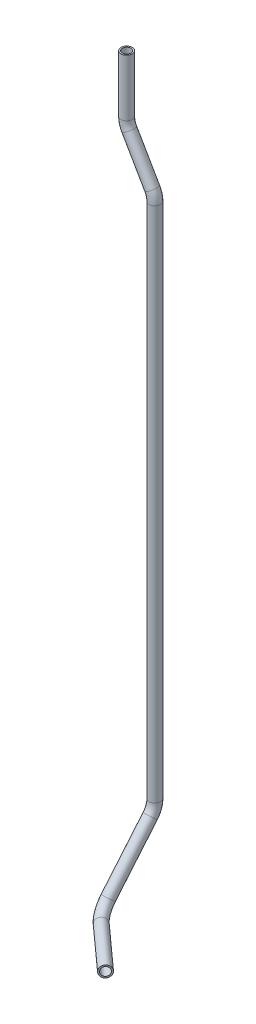
from build123d import *

# Parameters (mm, degrees)
SKETCH2_R   = 6
SKETCH2_R_2 = 4.5


with BuildPart() as part:
    # Sweep1: sweep along a curve in space
    with BuildLine() as sweep1_path:
        Line((0, 0, 0), (0, -60.373066959, 0))
        ThreePointArc((0, -60.373066959, 0), (0.715557648, -65.808266906, 0), (2.813466521, -70.873066959, 0))
        Line((2.813466521, -70.873066959, 0), (27.186533479, -113.088457268, 0))
        ThreePointArc((27.186533479, -113.088457268, 0), (29.284442352, -118.153257321, 0), (30, -123.588457268, 0))
        Line((30, -123.588457268, 0), (30, -672.73491671, 0))
        ThreePointArc((30, -672.73491671, 0), (30, -679.91733972, 1.266454963), (30, -686.233456513, 4.913066695))
        Line((30, -686.233456513, 4.913066695), (30, -739.344889262, 49.478850325))
        ThreePointArc((30, -739.344889262, 49.478850325), (32.668913393, -746.748845442, 58.094607638), (39.851540684, -749.5, 66.870367075))
        Line((39.851540684, -749.5, 66.870367075), (86.085931999, -749.5, 108.5))
    # Sketch2 → Sweep1 (sweep)
    with BuildSketch(Plane(origin=(0, 0, 0), x_dir=(1, 0, 0), z_dir=(0, 1, 0))):
        Circle(SKETCH2_R)
        Circle(SKETCH2_R_2, mode=Mode.SUBTRACT)
    sweep(path=sweep1_path.line)


solid = part.part
